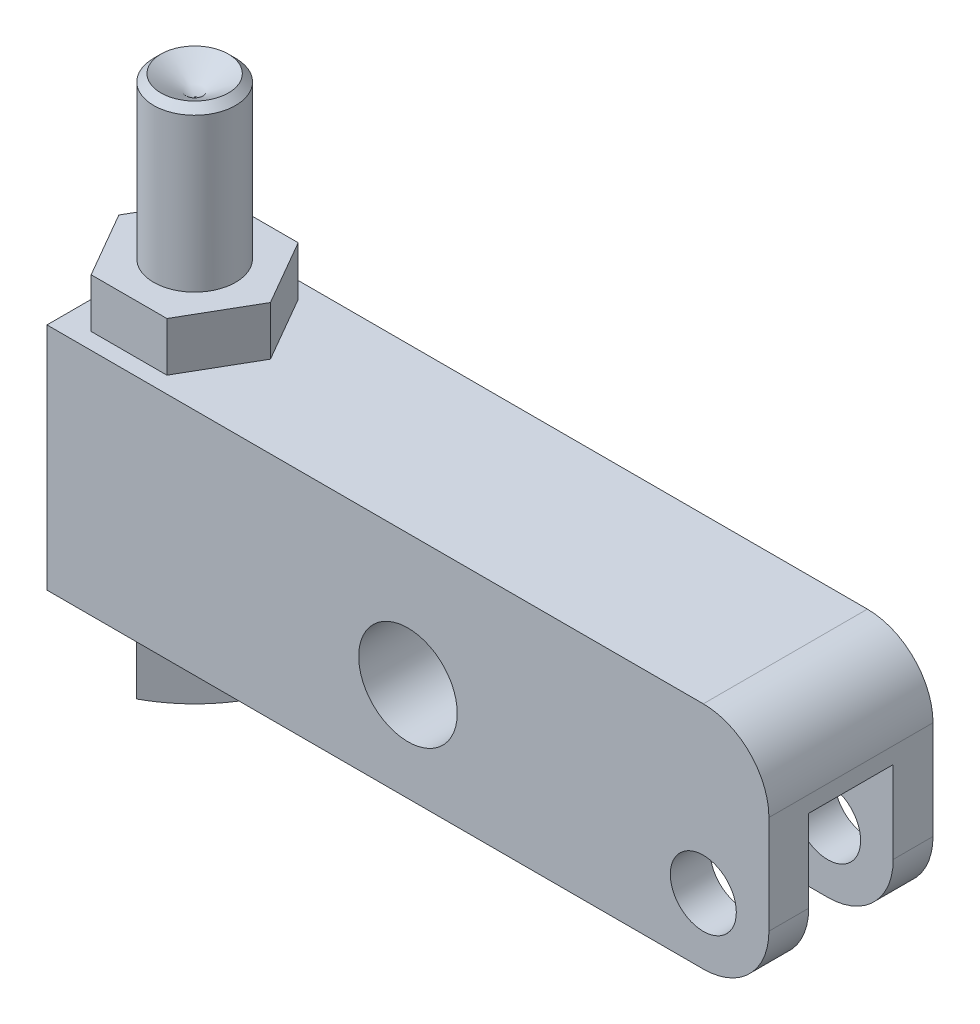
from build123d import *

# Parameters (mm, degrees)
SKETCH11_W         = 69.85
SKETCH11_H         = 22.225
SKETCH11_R         = 3.19405
SKETCH11_R_2       = 4.76885
EXTRUDE3_DEPTH     = 7.9375
CUT_EXTRUDE1_DEPTH = 14.3002
FILLET1_R          = 6.35
EXTRUDE4_DEPTH     = 4.7498
SKETCH15_R         = 13.386908493
CUT_EXTRUDE2_DEPTH = 6.969


with BuildPart() as part:
    # Sketch11 → Extrude3 (new body, symmetric)
    with BuildSketch(Plane.XY):
        with Locations((-28.575, 4.7625)):
            Rectangle(SKETCH11_W, SKETCH11_H)
        Circle(SKETCH11_R, mode=Mode.SUBTRACT)
        with Locations((-28.575, 3.175)):
            Circle(SKETCH11_R_2, mode=Mode.SUBTRACT)
    extrude(amount=EXTRUDE3_DEPTH, both=True)

    # Sketch12 → Cut-Extrude1 (cut)
    with BuildSketch(Plane.XZ.offset(6.35)):
        with BuildLine():
            Line((-7.9248, 4.0894), (6.35, 4.0894))
            Line((6.35, 4.0894), (6.35, -4.0894))
            Line((6.35, -4.0894), (-7.9248, -4.0894))
            ThreePointArc((-7.9248, -4.0894), (-12.0142, 0), (-7.9248, 4.0894))
        make_face()
    extrude(amount=-CUT_EXTRUDE1_DEPTH, mode=Mode.SUBTRACT)

    # Fillet1
    fillet1_edges = [part.edges().sort_by_distance(p)[0] for p in [
        (6.35, -6.35, -6.01345),
        (6.35, 15.875, 0),
        (6.35, -6.35, 6.01345),
    ]]
    fillet(fillet1_edges, radius=FILLET1_R)

    # Sketch13 → Extrude4 (add)
    with BuildSketch(Plane(origin=(0, 15.875, 0), x_dir=(1, 0, 0), z_dir=(0, 1, 0))):
        Polygon((-49.817651581, 0), (-53.483825791, 6.35), (-60.816174209, 6.35), (-64.482348419, 0), (-60.816174209, -6.35), (-53.483825791, -6.35), align=None)
    extrude(amount=EXTRUDE4_DEPTH)

    # Sketch14 → Revolve2 (revolve)
    with BuildSketch(Plane.XY):
        with BuildLine():
            Line((-57.15, 34.183051026), (-60.4139, 36.1442))
            Line((-60.4139, 36.1442), (-61.1124, 35.4457))
            Line((-61.1124, 35.4457), (-61.1124, -8.3058))
            Line((-61.1124, -8.3058), (-70.536908493, -8.3058))
            Line((-70.536908493, -8.3058), (-70.536908493, -9.0678))
            ThreePointArc((-70.536908493, -9.0678), (-64.331959482, -12.927219893), (-57.15, -14.2748))
            Line((-57.15, -14.2748), (-57.15, 34.183051026))
        make_face()
    revolve(axis=Axis((-57.15, 26.585218564, 0), (0, -1, 0)))

    # Sketch15 → Cut-Extrude2 (cut, through all)
    with BuildSketch(Plane(origin=(0, -8.3058, 0), x_dir=(1, 0, 0), z_dir=(0, 1, 0))):
        with Locations((-57.15, 0)):
            Circle(SKETCH15_R)
        Polygon((-57.15, 5.60367982), (-62.75367982, 0), (-57.15, -5.60367982), (-51.54632018, 0), align=None, mode=Mode.SUBTRACT)
    extrude(amount=-CUT_EXTRUDE2_DEPTH, mode=Mode.SUBTRACT)


solid = part.part
